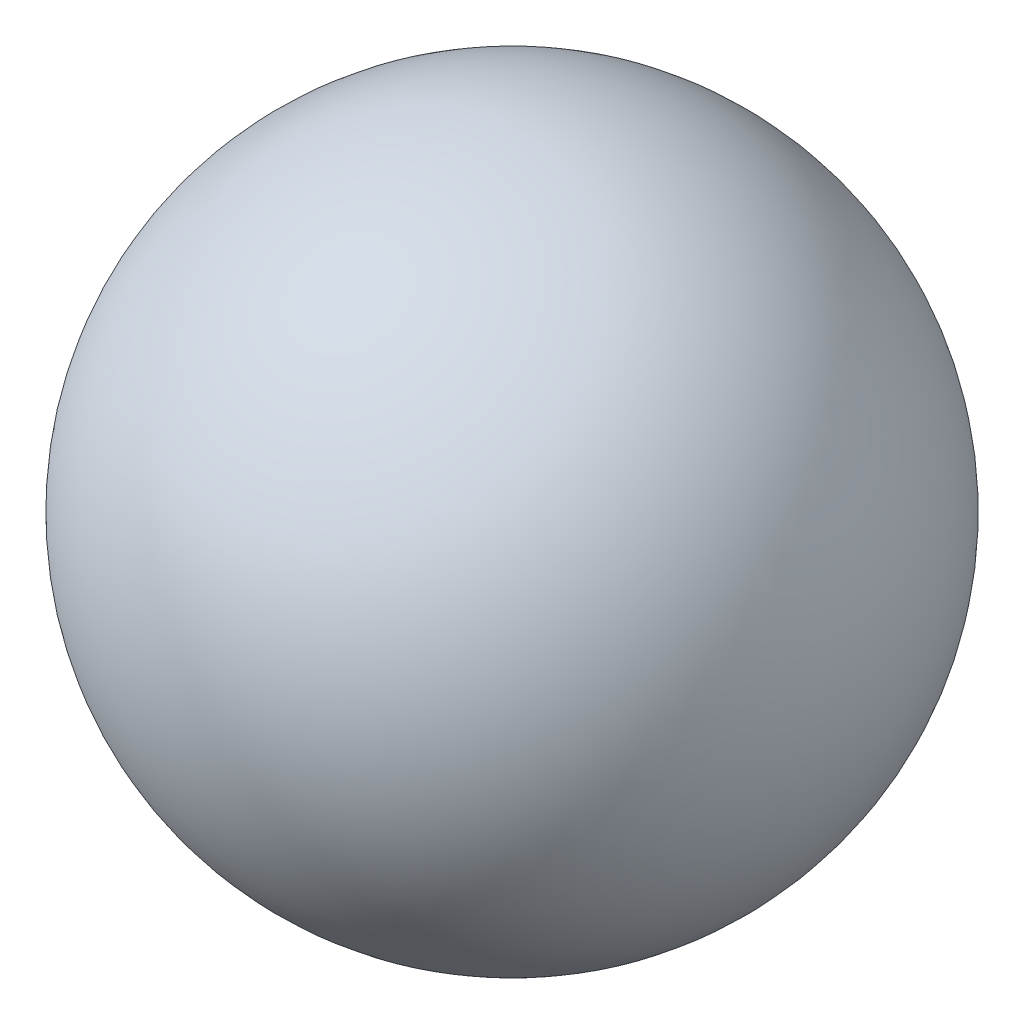
from build123d import *


with BuildPart() as part:
    # Çizim1 → Döndür1 (revolve)
    with BuildSketch(Plane.XY):
        with BuildLine():
            Line((0, 1), (0, -1))
            ThreePointArc((0, -1), (1, 0), (0, 1))
        make_face()
    revolve(axis=Axis((0, 1, 0), (0, -1, 0)))


solid = part.part
